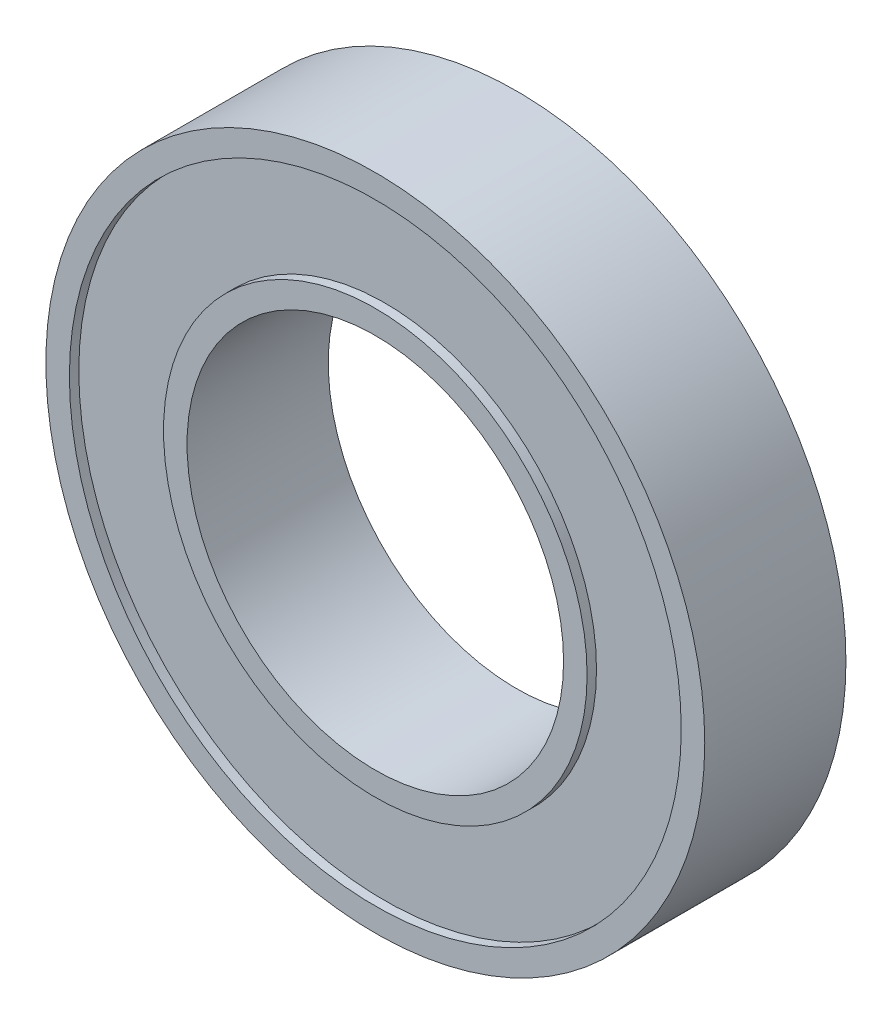
from build123d import *

# Parameters (mm, degrees)
SKETCH1_R           = 35
SKETCH1_R_2         = 20
BOSS_EXTRUDE1_DEPTH = 7.5
SKETCH2_R           = 32.5
SKETCH2_R_2         = 22.5
CUT_EXTRUDE1_DEPTH  = 1


with BuildPart() as part:
    # Sketch1 → Boss-Extrude1 (new body, symmetric)
    with BuildSketch(Plane.XY):
        Circle(SKETCH1_R)
        Circle(SKETCH1_R_2, mode=Mode.SUBTRACT)
    extrude(amount=BOSS_EXTRUDE1_DEPTH, both=True)

    # Sketch2 → Cut-Extrude1 (cut)
    with BuildSketch(Plane.XY.offset(7.5)):
        Circle(SKETCH2_R)
        Circle(SKETCH2_R_2, mode=Mode.SUBTRACT)
    cut_extrude1 = extrude(amount=-CUT_EXTRUDE1_DEPTH, mode=Mode.SUBTRACT)

    # Mirror1: Cut-Extrude1 across plane
    add(cut_extrude1.mirror(Plane.XY), mode=Mode.SUBTRACT)


solid = part.part
